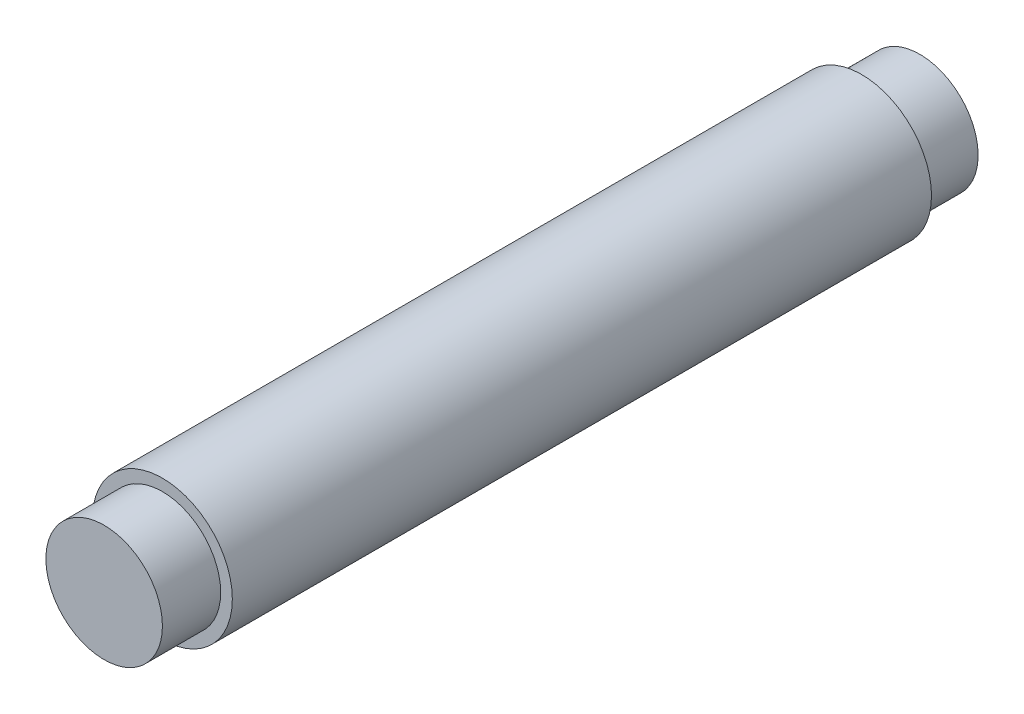
from build123d import *

# Parameters (mm, degrees)
SKETCH1_R           = 6
BOSS_EXTRUDE1_DEPTH = 60
SKETCH2_R           = 5
BOSS_EXTRUDE2_DEPTH = 5
SKETCH3_R           = 5
BOSS_EXTRUDE3_DEPTH = 5


with BuildPart() as part:
    # Sketch1 → Boss-Extrude1 (new body)
    with BuildSketch(Plane.XY):
        Circle(SKETCH1_R)
    extrude(amount=BOSS_EXTRUDE1_DEPTH)

    # Sketch2 → Boss-Extrude2 (add)
    with BuildSketch(Plane.XY.offset(60)):
        Circle(SKETCH2_R)
    extrude(amount=BOSS_EXTRUDE2_DEPTH)

    # Sketch3 → Boss-Extrude3 (add)
    with BuildSketch(Plane(origin=(0, 0, 0), x_dir=(-1, 0, 0), z_dir=(0, 0, -1))):
        Circle(SKETCH3_R)
    extrude(amount=BOSS_EXTRUDE3_DEPTH)


solid = part.part
